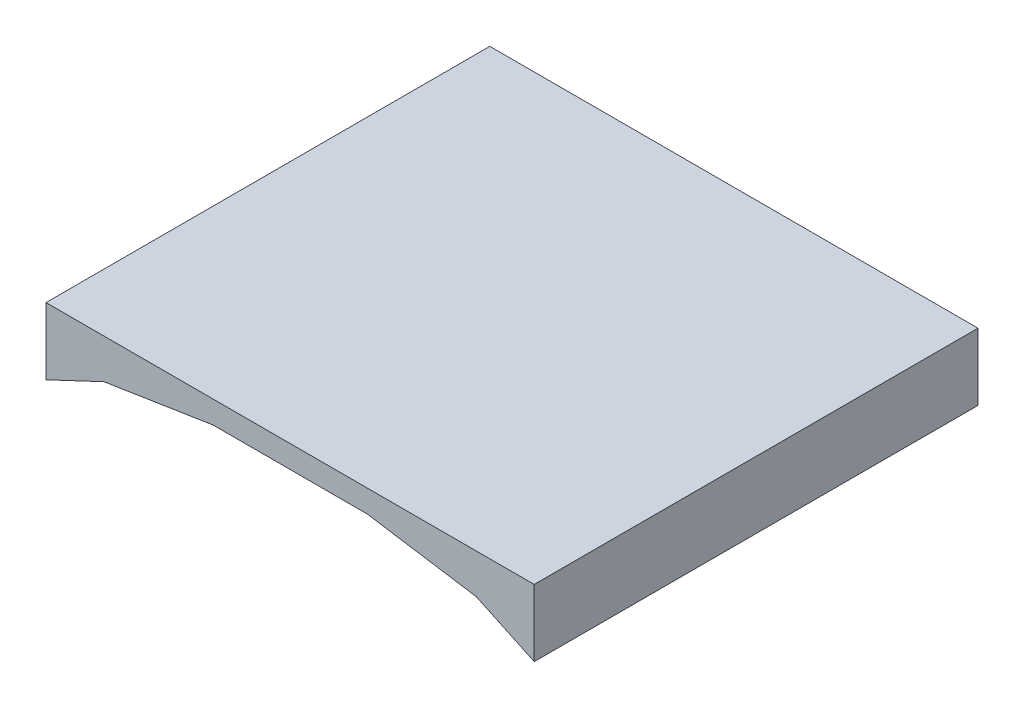
from build123d import *

# Parameters (mm, degrees)
BOSS_EXTRU_1_DEPTH = 50


with BuildPart() as part:
    # Esquisse1 → Boss.-Extru.1 (new body)
    with BuildSketch(Plane.XY):
        Polygon((-27.5, 0), (-20.980655657, 3.074629871), (-8.685004832, 5), (8.685004832, 5), (20.980655657, 3.074629871), (27.5, 0), (27.5, 7.535967642), (-27.5, 7.535967642), align=None)
    extrude(amount=BOSS_EXTRU_1_DEPTH)


solid = part.part
